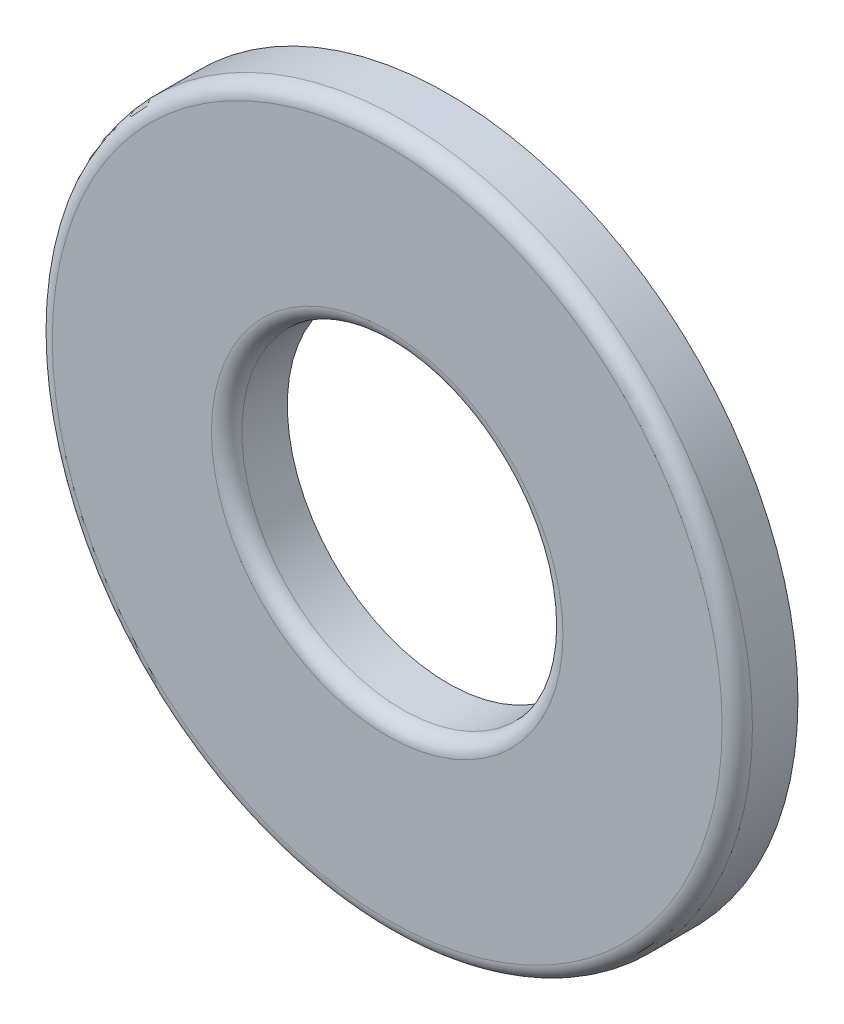
from build123d import *

# Parameters (mm, degrees)
SKETCH3_R                = 4.7625
SKETCH3_R_2              = 2.1844
BOSS_EXTRUDE1_DEPTH      = 0.41275
BOSS_EXTRUDE1_DEPTH_BACK = 0.41275
FILLET1_R                = 0.206375


with BuildPart() as part:
    # Sketch3 → Boss-Extrude1 (new body, two sides)
    with BuildSketch(Plane.XY) as boss_extrude1_sk:
        Circle(SKETCH3_R)
        Circle(SKETCH3_R_2, mode=Mode.SUBTRACT)
    extrude(amount=BOSS_EXTRUDE1_DEPTH)
    extrude(boss_extrude1_sk.sketch, amount=-BOSS_EXTRUDE1_DEPTH_BACK)

    # Fillet1
    fillet1_edges = [part.edges().sort_by_distance(p)[0] for p in [
        (-4.7625, 0, 0.41275),
        (-2.1844, 0, 0.41275),
    ]]
    fillet(fillet1_edges, radius=FILLET1_R)


solid = part.part
